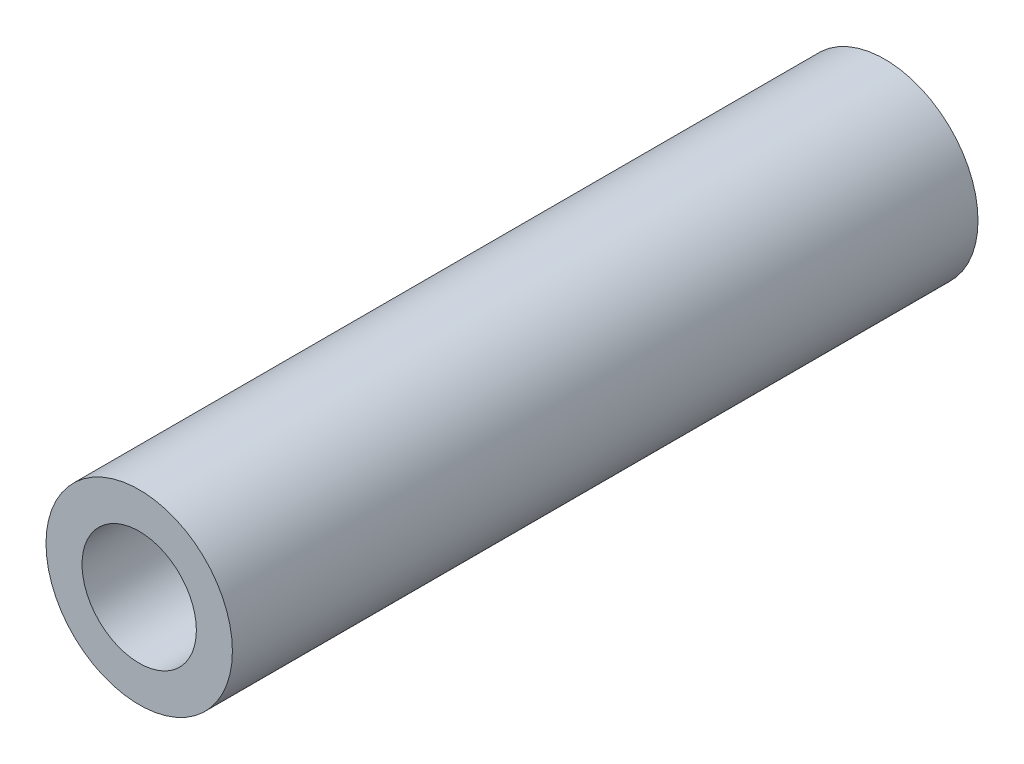
from build123d import *

# Parameters (mm, degrees)
SKETCH1_R      = 2.38125
SKETCH1_R_2    = 1.4605
EXTRUDE1_DEPTH = 9.525


with BuildPart() as part:
    # Sketch1 → Extrude1 (new body, symmetric)
    with BuildSketch(Plane.XY):
        Circle(SKETCH1_R)
        Circle(SKETCH1_R_2, mode=Mode.SUBTRACT)
    extrude(amount=EXTRUDE1_DEPTH, both=True)


solid = part.part
